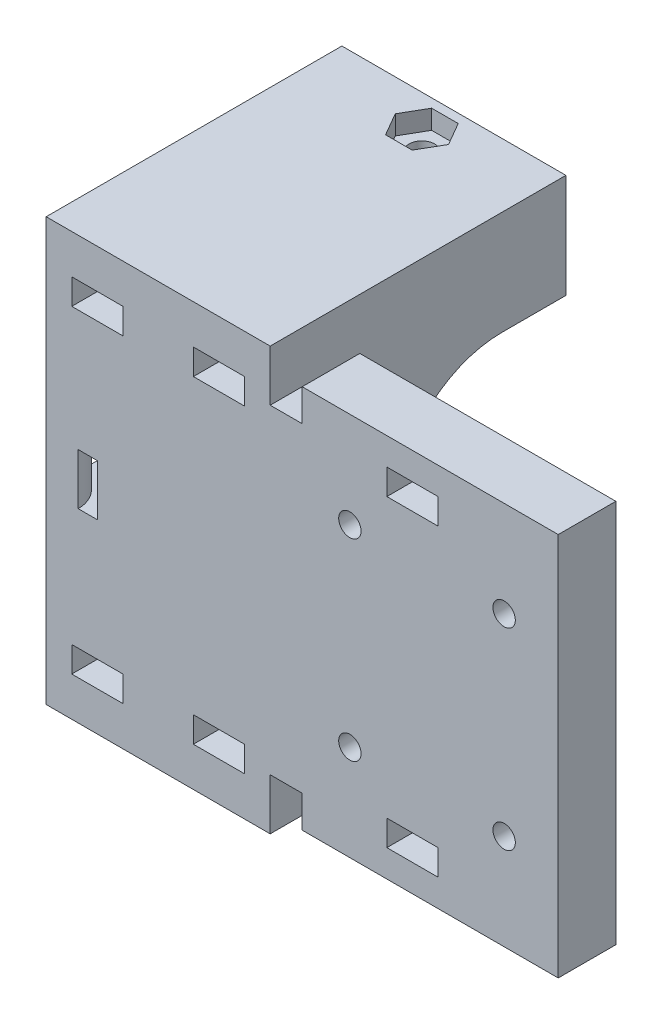
from build123d import *

# Parameters (mm, degrees)
SKETCH1_W                       = 40
SKETCH1_H                       = 90
BOSS_EXTRUDE1_DEPTH             = 9
SKETCH2_W                       = 9
SKETCH2_H                       = 50
BOSS_EXTRUDE2_DEPTH             = 40
BOSS_EXTRUDE3_DEPTH             = 35
SKETCH4_W                       = 35
SKETCH4_H                       = 8.25
BOSS_EXTRUDE4_DEPTH             = 10
SKETCH5_W                       = 35
SKETCH5_H                       = 46.2
BOSS_EXTRUDE5_DEPTH             = 8
SKETCH6_W                       = 35
SKETCH6_H                       = 46.2
BOSS_EXTRUDE6_DEPTH             = 8
SKETCH10_R                      = 2
CUT_EXTRUDE1_DEPTH              = 62.75
CUT_EXTRUDE1_DEPTH_BACK         = 29.25
SKETCH11_R                      = 4.25
CUT_EXTRUDE2_DEPTH              = 4
SKETCH12_R                      = 4.25
CUT_EXTRUDE3_DEPTH              = 4
SKETCH13_W                      = 8
SKETCH13_H                      = 4
CUT_EXTRUDE4_DEPTH              = 47.2
FILLET1_R                       = 4
CUT_EXTRUDE5_DEPTH              = 3
CUT_EXTRUDE6_DEPTH              = 3
SKETCH18_R                      = 1.75
CUT_EXTRUDE7_DEPTH              = 10
SKETCH19_W                      = 40
SKETCH19_H                      = 9
CUT_EXTRUDE8_DEPTH              = 12
SKETCH20_W                      = 40
SKETCH20_H                      = 9
CUT_EXTRUDE9_DEPTH              = 12
CUT_EXTRUDE10_REACH             = 18.25
SKETCH21_W                      = 8.5
SKETCH21_H                      = 5
CUT_EXTRUDE10_DIRECTION_2_REACH = 51.75
SKETCH22_W                      = 8
SKETCH22_H                      = 4
CUT_EXTRUDE11_DEPTH             = 14
CUT_EXTRUDE12_DEPTH             = 4
CUT_EXTRUDE12_DEPTH_BACK        = 4
SKETCH25_W                      = 40
SKETCH25_H                      = 9
CUT_EXTRUDE13_DEPTH             = 3
SKETCH26_W                      = 40
SKETCH26_H                      = 9
CUT_EXTRUDE14_DEPTH             = 3


with BuildPart() as part:
    # Sketch1 → Boss-Extrude1 (new body)
    with BuildSketch(Plane.XY):
        with Locations((-17, 0)):
            Rectangle(SKETCH1_W, SKETCH1_H)
    extrude(amount=BOSS_EXTRUDE1_DEPTH)

    # Sketch2 → Boss-Extrude2 (add)
    with BuildSketch(Plane.ZY.offset(37)):
        with Locations((4.5, 0)):
            Rectangle(SKETCH2_W, SKETCH2_H)
    extrude(amount=BOSS_EXTRUDE2_DEPTH)

    # Sketch3 → Boss-Extrude3 (add)
    with BuildSketch(Plane.ZY.offset(77)):
        with BuildLine():
            Line((0, -25), (0, 25))
            Line((0, 25), (-27.2, 25))
            Line((-27.2, 25), (-27.2, 16.75))
            ThreePointArc((-27.2, 16.75), (-15.355961415, 11.844038585), (-10.45, 0))
            ThreePointArc((-10.45, 0), (-15.355961415, -11.844038585), (-27.2, -16.75))
            Line((-27.2, -16.75), (-27.2, -25))
            Line((-27.2, -25), (0, -25))
        make_face()
    extrude(amount=-BOSS_EXTRUDE3_DEPTH)

    # Sketch4 → Boss-Extrude4 (add)
    with BuildSketch(Plane(origin=(0, 0, -27.2), x_dir=(-1, 0, 0), z_dir=(0, 0, -1))):
        with Locations((59.5, -20.875)):
            Rectangle(SKETCH4_W, SKETCH4_H)
        with Locations((59.5, 20.875)):
            Rectangle(SKETCH4_W, SKETCH4_H)
    extrude(amount=BOSS_EXTRUDE4_DEPTH)

    # Sketch5 → Boss-Extrude5 (add)
    with BuildSketch(Plane.XZ.offset(25)):
        with Locations((-59.5, -14.1)):
            Rectangle(SKETCH5_W, SKETCH5_H)
    extrude(amount=BOSS_EXTRUDE5_DEPTH)

    # Sketch6 → Boss-Extrude6 (add)
    with BuildSketch(Plane(origin=(0, 25, 0), x_dir=(1, 0, 0), z_dir=(0, 1, 0))):
        with Locations((-59.5, 14.1)):
            Rectangle(SKETCH6_W, SKETCH6_H)
    extrude(amount=BOSS_EXTRUDE6_DEPTH)

    # Sketch10 → Cut-Extrude1 (cut, two sides)
    with BuildSketch(Plane(origin=(0, -16.75, 0), x_dir=(1, 0, 0), z_dir=(0, 1, 0))) as cut_extrude1_sk:
        with Locations((-59.5, 32.2)):
            Circle(SKETCH10_R)
    extrude(amount=CUT_EXTRUDE1_DEPTH, mode=Mode.SUBTRACT)
    extrude(cut_extrude1_sk.sketch, amount=-CUT_EXTRUDE1_DEPTH_BACK, mode=Mode.SUBTRACT)

    # Sketch11 → Cut-Extrude2 (cut)
    with BuildSketch(Plane(origin=(0, -16.75, 0), x_dir=(1, 0, 0), z_dir=(0, 1, 0))):
        with Locations((-59.5, 32.2)):
            Circle(SKETCH11_R)
    extrude(amount=-CUT_EXTRUDE2_DEPTH, mode=Mode.SUBTRACT)

    # Sketch12 → Cut-Extrude3 (cut)
    with BuildSketch(Plane.XZ.offset(-16.75)):
        with Locations((-59.5, -32.2)):
            Circle(SKETCH12_R)
    extrude(amount=-CUT_EXTRUDE3_DEPTH, mode=Mode.SUBTRACT)

    # Sketch13 → Cut-Extrude4 (cut, through all)
    with BuildSketch(Plane(origin=(0, 0, -37.2), x_dir=(-1, 0, 0), z_dir=(0, 0, -1))):
        with Locations((50, 24.875)):
            Rectangle(SKETCH13_W, SKETCH13_H)
        with Locations((69, 24.875)):
            Rectangle(SKETCH13_W, SKETCH13_H)
        with Locations((50, -24.875)):
            Rectangle(SKETCH13_W, SKETCH13_H)
        with Locations((69, -24.875)):
            Rectangle(SKETCH13_W, SKETCH13_H)
    extrude(amount=-CUT_EXTRUDE4_DEPTH, mode=Mode.SUBTRACT)

    # Fillet1
    fillet1_edges = [part.edges().sort_by_distance(p)[0] for p in [
        (-69, 22.875, -37.2),
        (-50, -22.875, -37.2),
        (-69, -22.875, -37.2),
        (-50, 22.875, -37.2),
    ]]
    fillet(fillet1_edges, radius=FILLET1_R)

    # Sketch16 → Cut-Extrude5 (cut)
    with BuildSketch(Plane.XZ.offset(33)):
        Polygon((-57.421539031, -28.6), (-61.578460969, -28.6), (-63.656921938, -32.2), (-61.578460969, -35.8), (-57.421539031, -35.8), (-55.343078062, -32.2), align=None)
    extrude(amount=-CUT_EXTRUDE5_DEPTH, mode=Mode.SUBTRACT)

    # Sketch17 → Cut-Extrude6 (cut)
    with BuildSketch(Plane(origin=(0, 33, 0), x_dir=(1, 0, 0), z_dir=(0, 1, 0))):
        Polygon((-61.578460969, 28.6), (-57.421539031, 28.6), (-55.343078062, 32.2), (-57.421539031, 35.8), (-61.578460969, 35.8), (-63.656921938, 32.2), align=None)
    extrude(amount=-CUT_EXTRUDE6_DEPTH, mode=Mode.SUBTRACT)

    # Sketch18 → Cut-Extrude7 (cut)
    with BuildSketch(Plane(origin=(0, 0, 0), x_dir=(-1, 0, 0), z_dir=(0, 0, -1))):
        with Locations((5.45, 15.05)):
            Circle(SKETCH18_R)
        with Locations((5.45, -15.05)):
            Circle(SKETCH18_R)
        with Locations((29.55, -15.05)):
            Circle(SKETCH18_R)
        with Locations((29.55, 15.05)):
            Circle(SKETCH18_R)
    extrude(amount=-CUT_EXTRUDE7_DEPTH, mode=Mode.SUBTRACT)

    # Sketch19 → Cut-Extrude8 (cut)
    with BuildSketch(Plane(origin=(0, 45, 0), x_dir=(1, 0, 0), z_dir=(0, 1, 0))):
        with Locations((-17, -4.5)):
            Rectangle(SKETCH19_W, SKETCH19_H)
    extrude(amount=-CUT_EXTRUDE8_DEPTH, mode=Mode.SUBTRACT)

    # Sketch20 → Cut-Extrude9 (cut)
    with BuildSketch(Plane.XZ.offset(45)):
        with Locations((-17, 4.5)):
            Rectangle(SKETCH20_W, SKETCH20_H)
    extrude(amount=-CUT_EXTRUDE9_DEPTH, mode=Mode.SUBTRACT)

    # Cut-Extrude10: up to this face of the body (flat: up to its plane)
    cut_extrude10_end = Plane(part.part.faces().sort_by_distance((-63.629791847, -20.75, -32.2))[0])
    # Sketch21 → Cut-Extrude10 (cut, up to the picked face)
    with BuildSketch(Plane(origin=(0, -16.75, 0), x_dir=(1, 0, 0), z_dir=(0, 1, 0)), mode=Mode.PRIVATE) as cut_extrude10_sk1:
        with Locations((-59.5, 34.7)):
            Rectangle(SKETCH21_W, SKETCH21_H)
    cut_extrude10_tool1 = split(extrude(cut_extrude10_sk1.sketch, amount=-CUT_EXTRUDE10_REACH, mode=Mode.PRIVATE), bisect_by=cut_extrude10_end, keep=Keep.BOTH, mode=Mode.PRIVATE)
    add(cut_extrude10_tool1.solids().sort_by_distance((-59.5, -16.75, -34.7))[0], mode=Mode.SUBTRACT)

    # Cut-Extrude10 direction 2: up to this face of the body (flat: up to its plane)
    cut_extrude10_direction_2_end = Plane(part.part.faces().sort_by_distance((-63.629791847, 20.75, -32.2))[0])
    # Sketch21 → Cut-Extrude10 direction 2 (cut, up to the picked face)
    with BuildSketch(Plane(origin=(0, -16.75, 0), x_dir=(1, 0, 0), z_dir=(0, 1, 0)), mode=Mode.PRIVATE) as cut_extrude10_direction_2_sk1:
        with Locations((-59.5, 34.7)):
            Rectangle(SKETCH21_W, SKETCH21_H)
    cut_extrude10_direction_2_tool1 = split(extrude(cut_extrude10_direction_2_sk1.sketch, amount=CUT_EXTRUDE10_DIRECTION_2_REACH, mode=Mode.PRIVATE), bisect_by=cut_extrude10_direction_2_end, keep=Keep.BOTH, mode=Mode.PRIVATE)
    add(cut_extrude10_direction_2_tool1.solids().sort_by_distance((-59.5, -16.75, -34.7))[0], mode=Mode.SUBTRACT)

    # Sketch22 → Cut-Extrude11 (cut)
    with BuildSketch(Plane.XY.offset(9)):
        with Locations((-19.773502692, -23.75)):
            Rectangle(SKETCH22_W, SKETCH22_H)
        with Locations((-19.773502692, 23.75)):
            Rectangle(SKETCH22_W, SKETCH22_H)
    extrude(amount=-CUT_EXTRUDE11_DEPTH, mode=Mode.SUBTRACT)

    # Sketch23 → Cut-Extrude12 (cut, two sides)
    with BuildSketch(Plane(origin=(0, 0, 0), x_dir=(1, 0, 0), z_dir=(0, 1, 0))) as cut_extrude12_sk:
        with BuildLine():
            ThreePointArc((-69, -9), (-71.343145751, -3.343145751), (-77, -1))
            Line((-77, -1), (-77, -4))
            ThreePointArc((-77, -4), (-73.464466094, -5.464466094), (-72, -9))
            Line((-72, -9), (-69, -9))
        make_face()
        with BuildLine():
            Line((-77, -4), (-77, -1))
            ThreePointArc((-77, -1), (-82.656854249, -14.656854249), (-69, -9))
            Line((-69, -9), (-72, -9))
            ThreePointArc((-72, -9), (-80.535533906, -12.535533906), (-77, -4))
        make_face()
    extrude(amount=CUT_EXTRUDE12_DEPTH, mode=Mode.SUBTRACT)
    extrude(cut_extrude12_sk.sketch, amount=-CUT_EXTRUDE12_DEPTH_BACK, mode=Mode.SUBTRACT)

    # Sketch25 → Cut-Extrude13 (cut)
    with BuildSketch(Plane(origin=(0, 33, 0), x_dir=(1, 0, 0), z_dir=(0, 1, 0))):
        with Locations((-17, -4.5)):
            Rectangle(SKETCH25_W, SKETCH25_H)
    extrude(amount=-CUT_EXTRUDE13_DEPTH, mode=Mode.SUBTRACT)

    # Sketch26 → Cut-Extrude14 (cut)
    with BuildSketch(Plane.XZ.offset(33)):
        with Locations((-17, 4.5)):
            Rectangle(SKETCH26_W, SKETCH26_H)
    extrude(amount=-CUT_EXTRUDE14_DEPTH, mode=Mode.SUBTRACT)


solid = part.part
